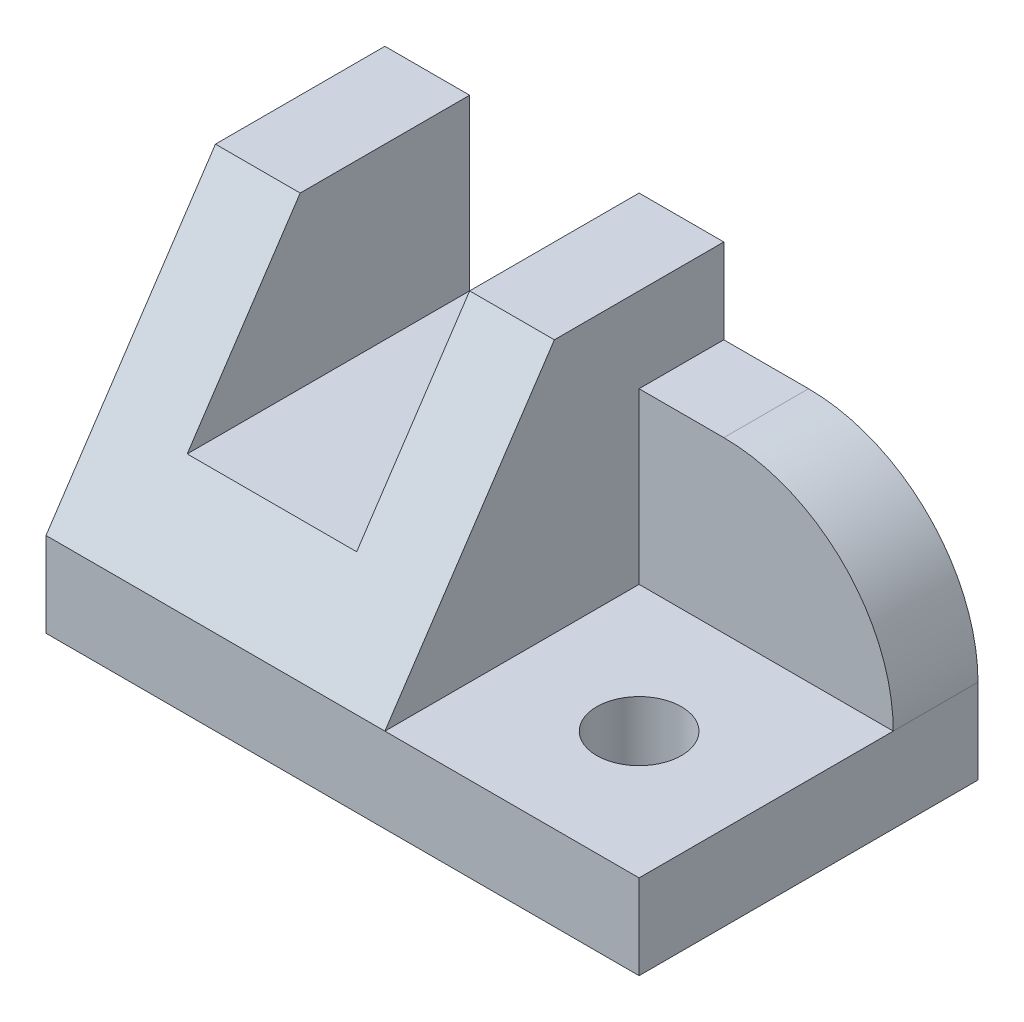
from build123d import *

# Parameters (mm, degrees)
SKETCH_1_W          = 15
SKETCH_1_H          = 15
SKETCH_1_R          = 2.5
EXTRUDE_1_DEPTH     = 5
SKETCH_1_3_W        = 15
SKETCH_1_3_H        = 5
EXTRUDE_2_DEPTH     = 15
EXTRUDE_3_DEPTH     = 20
CUT_EXTRUDE_1_DEPTH = 20
SKETCH_3_W          = 10
SKETCH_3_H          = 10
CUT_EXTRUDE_2_DEPTH = 20
FILLET_1_R          = 10
SCALE_1_SCALE       = 0.2


with BuildPart() as part:
    # 草圖1 → 填料-伸長1 (new body)
    with BuildSketch(Plane(origin=(0, 0, 0), x_dir=(1, 0, 0), z_dir=(0, 1, 0))):
        with Locations((10, -2.5)):
            Rectangle(SKETCH_1_W, SKETCH_1_H)
        with Locations((10, -2.5)):
            Circle(SKETCH_1_R, mode=Mode.SUBTRACT)
    extrude(amount=EXTRUDE_1_DEPTH)

    # 草圖1<3> → 填料-伸長2 (add)
    with BuildSketch(Plane(origin=(0, 0, 0), x_dir=(1, 0, 0), z_dir=(0, 1, 0))):
        with Locations((10, 7.5)):
            Rectangle(SKETCH_1_3_W, SKETCH_1_3_H)
    extrude(amount=EXTRUDE_2_DEPTH)

    # 草圖1<4> → 填料-伸長3 (add)
    with BuildSketch(Plane(origin=(0, 0, 0), x_dir=(1, 0, 0), z_dir=(0, 1, 0))):
        Polygon((-17.5, 10), (-17.5, -10), (2.5, -10), (2.5, 5), (2.5, 10), align=None)
    extrude(amount=EXTRUDE_3_DEPTH)

    # 草圖2 → 除料-伸長1 (cut)
    with BuildSketch(Plane(origin=(2.5, 0, 0), x_dir=(0, 0, -1), z_dir=(1, 0, 0))):
        Polygon((-10, 5), (0, 20), (-10, 20), align=None)
    extrude(amount=-CUT_EXTRUDE_1_DEPTH, mode=Mode.SUBTRACT)

    # 草圖3 → 除料-伸長2 (cut)
    with BuildSketch(Plane(origin=(0, 0, -10), x_dir=(-1, 0, 0), z_dir=(0, 0, -1))):
        with Locations((7.5, 15)):
            Rectangle(SKETCH_3_W, SKETCH_3_H)
    extrude(amount=-CUT_EXTRUDE_2_DEPTH, mode=Mode.SUBTRACT)

    # 圓角1
    fillet_1_edges = [part.edges().sort_by_distance(p)[0] for p in [
        (17.5, 15, -7.5),
    ]]
    fillet(fillet_1_edges, radius=FILLET_1_R)


with BuildPart() as part_1:
    # 縮放比例1: scaled about (-2.616743612, 6.613370919, -1.498562555)
    add(part.part.scale(SCALE_1_SCALE).moved(Location((-2.09339489, 5.290696735, -1.198850044))))


solid = part_1.part
